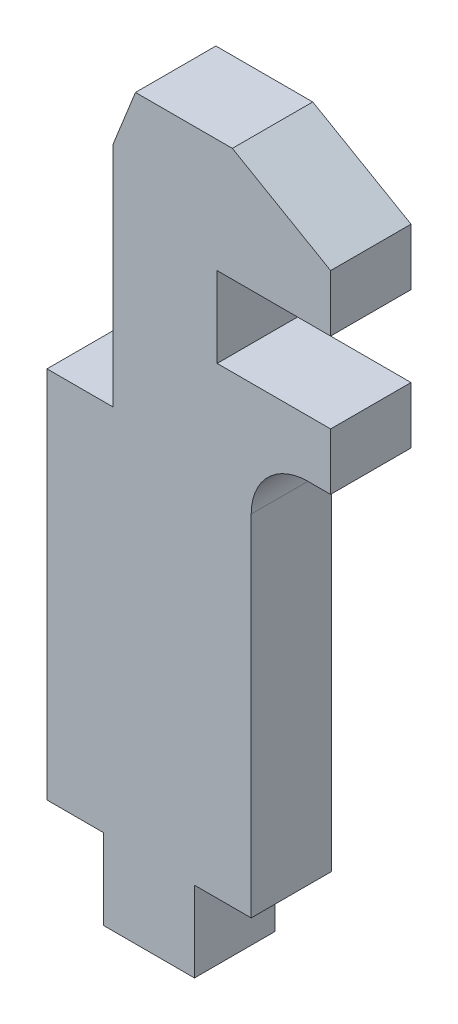
from build123d import *

# Parameters (mm, degrees)
BOSS_EXTRUDE1_DEPTH = 2.25
BOSS_EXTRUDE2_DEPTH = 2.249999945
SKETCH4_W           = 3.683
SKETCH4_H           = 4.5
BOSS_EXTRUDE3_DEPTH = 1.143


with BuildPart() as part:
    # Sketch1 → Boss-Extrude1 (new body, symmetric)
    with BuildSketch(Plane.XY):
        with BuildLine():
            Line((0, 10.45), (0, -10.45))
            Line((0, -10.45), (3.175, -10.45))
            Line((3.175, -10.45), (3.175, -14.95))
            Line((3.175, -14.95), (8.255, -14.95))
            Line((8.255, -14.95), (8.255, -10.45))
            Line((8.255, -10.45), (11.43, -10.45))
            Line((11.43, -10.45), (11.43, 9.125))
            ThreePointArc((11.43, 9.125), (12.35993597, 11.37006403), (14.605, 12.3))
            Line((14.605, 12.3), (15.875, 12.3))
            Line((15.875, 12.3), (15.875, 15.475))
            Line((15.875, 15.475), (9.525, 15.475))
            Line((9.525, 15.475), (9.525, 19.975))
            Line((9.525, 19.975), (15.875, 19.975))
            Line((15.875, 19.975), (15.875, 23.15))
            Line((15.875, 23.15), (3.683, 23.15))
            Line((3.683, 23.15), (3.683, 10.45))
            Line((3.683, 10.45), (0, 10.45))
        make_face()
    extrude(amount=BOSS_EXTRUDE1_DEPTH, both=True)

    # Sketch2 → Boss-Extrude2 (add, symmetric)
    with BuildSketch(Plane.XY):
        Polygon((3.683, 23.15), (4.953, 26.325), (10.375738686, 26.325), (15.875, 23.15), align=None)
    extrude(amount=BOSS_EXTRUDE2_DEPTH, both=True)

    # Sketch4 → Boss-Extrude3 (add)
    with BuildSketch(Plane(origin=(0, 8.545, 0), x_dir=(1, 0, 0), z_dir=(0, 1, 0))):
        with Locations((1.8415, 0)):
            Rectangle(SKETCH4_W, SKETCH4_H)
    extrude(amount=BOSS_EXTRUDE3_DEPTH)


solid = part.part
